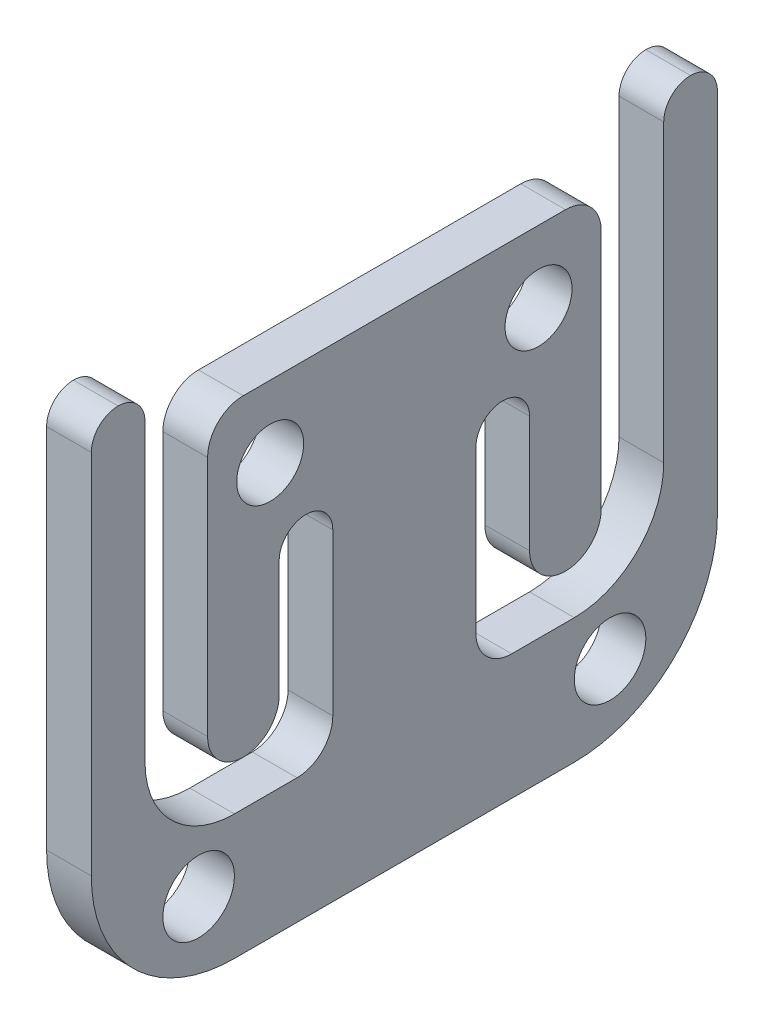
from build123d import *

# Parameters (mm, degrees)
SKETCH1_R           = 1.872075336
SKETCH1_R_2         = 2
BOSS_EXTRUDE1_DEPTH = 2.5


with BuildPart() as part:
    # Sketch1 → Boss-Extrude1 (new body)
    with BuildSketch(Plane(origin=(0, 0, 0), x_dir=(0, 0, -1), z_dir=(1, 0, 0))):
        with BuildLine():
            Line((23.5, 7), (27, 7))
            ThreePointArc((27, 7), (30.535533906, 8.464466094), (32, 12))
            Line((32, 12), (32, 28.501))
            ThreePointArc((32, 28.501), (32.439046935, 29.560953065), (33.499, 30))
            Line((33.499, 30), (33.501, 30))
            ThreePointArc((33.501, 30), (34.560953065, 29.560953065), (35, 28.501))
            Line((35, 28.501), (35, 8))
            ThreePointArc((35, 8), (32.656854249, 2.343145751), (27, 0))
            Line((27, 0), (8, 0))
            ThreePointArc((8, 0), (2.343145751, 2.343145751), (0, 8))
            Line((0, 8), (0, 28.501))
            ThreePointArc((0, 28.501), (0.439046935, 29.560953065), (1.499, 30))
            Line((1.499, 30), (1.501, 30))
            ThreePointArc((1.501, 30), (2.560953065, 29.560953065), (3, 28.501))
            Line((3, 28.501), (3, 12))
            ThreePointArc((3, 12), (4.464466094, 8.464466094), (8, 7))
            Line((8, 7), (11.5, 7))
            ThreePointArc((11.5, 7), (12.914213562, 7.585786438), (13.5, 9))
            Line((13.5, 9), (13.5, 18))
            ThreePointArc((13.5, 18), (12, 19.5), (10.5, 18))
            Line((10.5, 18), (10.5, 11.49))
            ThreePointArc((10.5, 11.49), (9.917142495, 10.082857505), (8.51, 9.5))
            Line((8.51, 9.5), (8.49, 9.5))
            ThreePointArc((8.49, 9.5), (7.082857505, 10.082857505), (6.5, 11.49))
            Line((6.5, 11.49), (6.5, 25.01))
            ThreePointArc((6.5, 25.01), (7.082857505, 26.417142495), (8.49, 27))
            Line((8.49, 27), (26.51, 27))
            ThreePointArc((26.51, 27), (27.917142495, 26.417142495), (28.5, 25.01))
            Line((28.5, 25.01), (28.5, 11.49))
            ThreePointArc((28.5, 11.49), (27.917142495, 10.082857505), (26.51, 9.5))
            Line((26.51, 9.5), (26.49, 9.5))
            ThreePointArc((26.49, 9.5), (25.082857505, 10.082857505), (24.5, 11.49))
            Line((24.5, 11.49), (24.5, 18))
            ThreePointArc((24.5, 18), (23, 19.5), (21.5, 18))
            Line((21.5, 18), (21.5, 9))
            ThreePointArc((21.5, 9), (22.085786438, 7.585786438), (23.5, 7))
        make_face()
        with Locations((10, 23)):
            Circle(SKETCH1_R, mode=Mode.SUBTRACT)
        with Locations((25, 23)):
            Circle(SKETCH1_R, mode=Mode.SUBTRACT)
        with Locations((6, 4)):
            Circle(SKETCH1_R_2, mode=Mode.SUBTRACT)
        with Locations((29, 4)):
            Circle(SKETCH1_R_2, mode=Mode.SUBTRACT)
    extrude(amount=BOSS_EXTRUDE1_DEPTH)


solid = part.part
